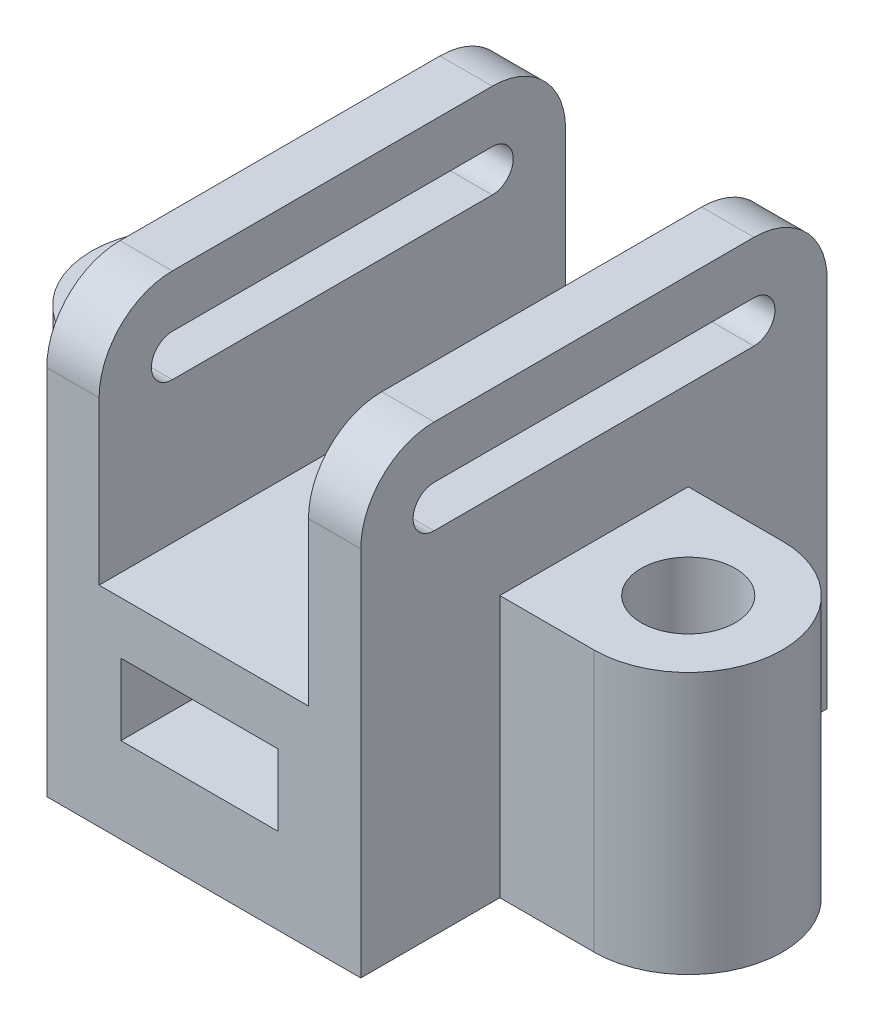
from build123d import *

# Parameters (mm, degrees)
SKETCH1_W             = 10
SKETCH1_H             = 89.12
BOSS_EXTRUDE1_DEPTH   = 85
BOSS_EXTRUDE1_2_DEPTH = 85
SKETCH1_5_W           = 40
SKETCH1_5_H           = 89.12
SKETCH1_5_W_2         = 20
SKETCH1_5_H_2         = 20
BOSS_EXTRUDE2_DEPTH   = 40
SKETCH1_6_R           = 9
BOSS_EXTRUDE3_DEPTH   = 50
CUT_EXTRUDE1_DEPTH    = 43
CUT_EXTRUDE2_DEPTH    = 86
SKETCH4_W             = 30
SKETCH4_H             = 13.637460926
CUT_EXTRUDE3_DEPTH    = 103


with BuildPart() as part:
    # Sketch1 → Boss-Extrude1 (new body)
    with BuildSketch(Plane(origin=(0, 0, 0), x_dir=(1, 0, 0), z_dir=(0, 1, 0))):
        with Locations((25, 0)):
            Rectangle(SKETCH1_W, SKETCH1_H)
    extrude(amount=BOSS_EXTRUDE1_DEPTH)



with BuildPart() as body_2:
    # Sketch1 → Boss-Extrude1 2 (new body)
    with BuildSketch(Plane(origin=(0, 0, 0), x_dir=(1, 0, 0), z_dir=(0, 1, 0))):
        with Locations((-25, 0)):
            Rectangle(SKETCH1_W, SKETCH1_H)
    extrude(amount=BOSS_EXTRUDE1_2_DEPTH)


with BuildPart() as part_1:
    add(part.part)

    add(body_2.part)  # Boss-Extrude2 merges body 2
    # Sketch1_5 → Boss-Extrude2 (add)
    with BuildSketch(Plane(origin=(0, 0, 0), x_dir=(1, 0, 0), z_dir=(0, 1, 0))):
        Rectangle(SKETCH1_5_W, SKETCH1_5_H)
        Rectangle(SKETCH1_5_W_2, SKETCH1_5_H_2, mode=Mode.SUBTRACT)
    extrude(amount=BOSS_EXTRUDE2_DEPTH)

    # Sketch1_6 → Boss-Extrude3 (add)
    # profile 1 of 2: a face of its own
    with BuildSketch(Plane(origin=(0, 0, 0), x_dir=(1, 0, 0), z_dir=(0, 1, 0))):
        with BuildLine():
            Line((30, 18), (30, -18))
            Line((30, -18), (48, -18))
            ThreePointArc((48, -18), (66, 0), (48, 18))
            Line((48, 18), (30, 18))
        make_face()
        with Locations((48, 0)):
            Circle(SKETCH1_6_R, mode=Mode.SUBTRACT)
    # profile 2 of 2: a face of its own
    with BuildSketch(Plane(origin=(0, 0, 0), x_dir=(1, 0, 0), z_dir=(0, 1, 0))):
        with BuildLine():
            Line((-48, -18), (-30, -18))
            Line((-30, -18), (-30, 18))
            Line((-30, 18), (-48, 18))
            ThreePointArc((-48, 18), (-66, 0), (-48, -18))
        make_face()
        with Locations((-48, 0)):
            Circle(SKETCH1_6_R, mode=Mode.SUBTRACT)
    extrude(amount=BOSS_EXTRUDE3_DEPTH)

    # Sketch2 → Cut-Extrude1 (cut, symmetric)
    with BuildSketch(Plane(origin=(0, 0, 0), x_dir=(0, 0, -1), z_dir=(1, 0, 0))):
        with BuildLine():
            ThreePointArc((-30.56, 75), (-34.56, 71), (-30.56, 67))
            Line((-30.56, 67), (-17.143592135, 67))
            Line((-17.143592135, 67), (17.143592135, 67))
            Line((17.143592135, 67), (30.56, 67))
            ThreePointArc((30.56, 67), (34.56, 71), (30.56, 75))
            Line((30.56, 75), (17.143592135, 75))
            Line((17.143592135, 75), (-17.143592135, 75))
            Line((-17.143592135, 75), (-30.56, 75))
        make_face()
    extrude(amount=CUT_EXTRUDE1_DEPTH, both=True, mode=Mode.SUBTRACT)

    # Sketch3 → Cut-Extrude2 (cut)
    with BuildSketch(Plane(origin=(30, 0, 0), x_dir=(0, 0, -1), z_dir=(1, 0, 0))):
        with BuildLine():
            ThreePointArc((-44.56, 71), (-40.459494937, 80.899494937), (-30.56, 85))
            Line((-30.56, 85), (-44.56, 85))
            Line((-44.56, 85), (-44.56, 71))
        make_face()
        with BuildLine():
            Line((44.56, 85), (30.56, 85))
            ThreePointArc((30.56, 85), (40.459494937, 80.899494937), (44.56, 71))
            Line((44.56, 71), (44.56, 85))
        make_face()
    extrude(amount=-CUT_EXTRUDE2_DEPTH, mode=Mode.SUBTRACT)

    # Sketch4 → Cut-Extrude3 (cut)
    with BuildSketch(Plane.XY.offset(44.56)):
        with Locations((-0.820162859, 23.181269537)):
            Rectangle(SKETCH4_W, SKETCH4_H)
    extrude(amount=-CUT_EXTRUDE3_DEPTH, mode=Mode.SUBTRACT)


solid = part_1.part
